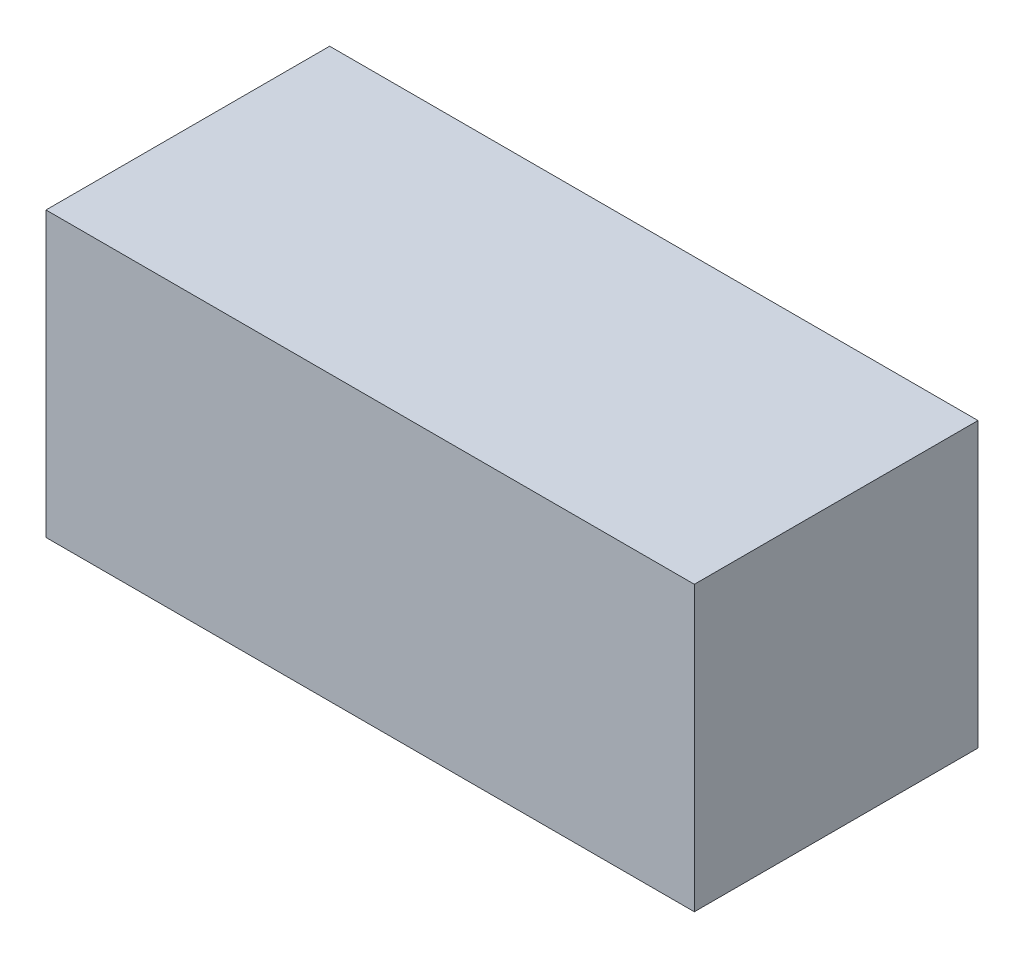
from build123d import *

# Parameters (mm, degrees)
SKETCH_1_W      = 160
SKETCH_1_H      = 70
EXTRUDE_1_DEPTH = 70
SKETCH_2_W      = 1.13974359
SKETCH_2_H      = 12.7
EXTRUDE_2_DEPTH = 1


with BuildPart() as part:
    # 스케치1 → 보스-돌출1 (new body)
    with BuildSketch(Plane.XY):
        with Locations((80, -35)):
            Rectangle(SKETCH_1_W, SKETCH_1_H)
    extrude(amount=EXTRUDE_1_DEPTH)

    # 스케치2 → 보스-돌출2 (add)
    with BuildSketch(Plane(origin=(0, 0, 0), x_dir=(-1, 0, 0), z_dir=(0, 0, -1))):
        with BuildLine():
            Line((-138.713958847, -29.383712204), (-139.711234488, -30.146933358))
            add(Edge.make_bspline(
                [(-139.711234488, -30.146933358), (-139.782375854, -30.062148268), (-139.923699447, -29.893721174), (-140.151062839, -29.657212541), (-140.388014515, -29.435632878), (-140.634463897, -29.227926629), (-140.894846988, -29.041357222), (-141.162856172, -28.866202077), (-141.442974793, -28.709201999), (-141.830331087, -28.518836307), (-142.33705328, -28.320185973), (-142.97493741, -28.153622819), (-143.640820539, -28.047591696), (-144.095108972, -28.036107843), (-144.326178398, -28.030266692)],
                knots=[0, 0, 0, 0, 0.00033196, 0.000659444, 0.000983431, 0.001304932, 0.001625525, 0.001943778, 0.002265016, 0.002588143, 0.003238217, 0.003893566, 0.004562806, 0.005255583, 0.005255583, 0.005255583, 0.005255583], degree=3))
            add(Edge.make_bspline(
                [(-144.326178398, -28.030266692), (-144.453480656, -28.031732498), (-144.706903686, -28.034650508), (-145.082999576, -28.073146477), (-145.452072647, -28.127252867), (-145.813882824, -28.207536183), (-146.16796956, -28.309036829), (-146.516647704, -28.430323331), (-146.854869023, -28.580382322), (-147.187312345, -28.746238008), (-147.505825482, -28.933571879), (-147.807196655, -29.137908898), (-148.09032671, -29.356962477), (-148.355439617, -29.591553634), (-148.602806401, -29.840625891), (-148.830634643, -30.106833645), (-149.038135989, -30.389325817), (-149.22942348, -30.684377325), (-149.400738255, -30.99112874), (-149.544175246, -31.310715424), (-149.671193833, -31.637664598), (-149.771702513, -31.975670239), (-149.851257188, -32.322353989), (-149.906148995, -32.678646277), (-149.944207162, -33.043802771), (-149.947110661, -33.291305134), (-149.948574232, -33.416063967)],
                knots=[0, 0, 0, 0, 0.000381746, 0.00075995, 0.001133062, 0.001500343, 0.001870765, 0.002237676, 0.002606812, 0.002979993, 0.003351741, 0.00371443, 0.004071661, 0.004424911, 0.004775707, 0.005123948, 0.005475039, 0.005826461, 0.006178335, 0.006527846, 0.006876532, 0.007229865, 0.007584733, 0.007942761, 0.008310834, 0.008684951, 0.008684951, 0.008684951, 0.008684951], degree=3))
            add(Edge.make_bspline(
                [(-149.948574232, -33.416063967), (-149.943995631, -33.603774757), (-149.935006156, -33.972319993), (-149.855002201, -34.51214478), (-149.733426584, -35.029291225), (-149.551215777, -35.520526653), (-149.326538079, -35.991908409), (-149.042636431, -36.43546082), (-148.713827853, -36.85788664), (-148.335460674, -37.249202479), (-147.920330999, -37.606666568), (-147.474931434, -37.921447249), (-147.000371304, -38.183846966), (-146.501890389, -38.402199686), (-145.975652775, -38.570045526), (-145.422604778, -38.688206774), (-144.843949252, -38.765285544), (-144.448546001, -38.772664926), (-144.247312212, -38.776420538)],
                knots=[0, 0, 0, 0, 0.000562815, 0.001105012, 0.001633818, 0.00215373, 0.002673724, 0.003197432, 0.003730267, 0.004277248, 0.00482748, 0.005371661, 0.005910344, 0.006451519, 0.007001839, 0.007564217, 0.008146414, 0.008749794, 0.008749794, 0.008749794, 0.008749794], degree=3))
            add(Edge.make_bspline(
                [(-144.247312212, -38.776420538), (-144.025596741, -38.77029268), (-143.589207654, -38.758231589), (-142.949243673, -38.656053743), (-142.336611038, -38.490380727), (-141.751276795, -38.258522551), (-141.194891079, -37.957114221), (-140.666583197, -37.59172478), (-140.165907213, -37.158878544), (-139.864839989, -36.828376907), (-139.711234488, -36.659753871)],
                knots=[0, 0, 0, 0, 0.000664826, 0.001308536, 0.001938654, 0.00256556, 0.003192755, 0.00383282, 0.004489298, 0.005173128, 0.005173128, 0.005173128, 0.005173128], degree=3))
            Line((-139.711234488, -36.659753871), (-138.713958847, -37.415342813))
            add(Edge.make_bspline(
                [(-138.713958847, -37.415342813), (-138.794215989, -37.518896625), (-138.954345844, -37.72550823), (-139.213636363, -38.016779863), (-139.486785414, -38.290751649), (-139.775821847, -38.545214731), (-140.077420691, -38.785260935), (-140.396997367, -39.004070437), (-140.730350714, -39.20469736), (-141.076351252, -39.388400772), (-141.434631361, -39.551386211), (-141.804761739, -39.690918454), (-142.18514697, -39.811114482), (-142.575804444, -39.910000081), (-142.977544475, -39.987183728), (-143.388917339, -40.038780834), (-143.810810886, -40.074130067), (-144.095441185, -40.077351932), (-144.239680001, -40.07898464)],
                knots=[0, 0, 0, 0, 0.00039295, 0.000784017, 0.001168988, 0.001552873, 0.001938676, 0.002324679, 0.002713864, 0.003105353, 0.00349929, 0.003893826, 0.004291304, 0.004695459, 0.005102104, 0.005517692, 0.005938765, 0.006371376, 0.006371376, 0.006371376, 0.006371376], degree=3))
            add(Edge.make_bspline(
                [(-144.239680001, -40.07898464), (-144.376272736, -40.078033982), (-144.646367954, -40.076154172), (-145.045143424, -40.045702593), (-145.43336276, -40.004156405), (-145.809916403, -39.941599358), (-146.176859226, -39.867778467), (-146.530864776, -39.768822764), (-146.875416539, -39.657972931), (-147.209130232, -39.527689122), (-147.532289714, -39.38067326), (-147.843852687, -39.214515317), (-148.143675856, -39.030612551), (-148.434706955, -38.833018656), (-148.712646758, -38.615386732), (-148.979903836, -38.38073923), (-149.237976821, -38.12986702), (-149.397643707, -37.948965123), (-149.477921187, -37.858011083)],
                knots=[0, 0, 0, 0, 0.000409666, 0.000810065, 0.001199174, 0.001580615, 0.001954827, 0.00232143, 0.002682661, 0.003040299, 0.003395496, 0.003747176, 0.004098847, 0.004450261, 0.004801913, 0.005157073, 0.005516877, 0.005880706, 0.005880706, 0.005880706, 0.005880706], degree=3))
            add(Edge.make_bspline(
                [(-149.477921187, -37.858011083), (-149.60650195, -37.700018769), (-149.862111138, -37.385941562), (-150.189138618, -36.876903859), (-150.469074033, -36.345433501), (-150.695409516, -35.788738331), (-150.872348577, -35.208067526), (-150.994926056, -34.603128373), (-151.074579021, -33.97448584), (-151.083687783, -33.546906636), (-151.088317821, -33.32956557)],
                knots=[0, 0, 0, 0, 0.000610709, 0.001214046, 0.001811469, 0.002410515, 0.003014109, 0.003629806, 0.004260284, 0.004912063, 0.004912063, 0.004912063, 0.004912063], degree=3))
            add(Edge.make_bspline(
                [(-151.088317821, -33.32956557), (-151.08267469, -33.10112721), (-151.071572183, -32.651688998), (-150.977244582, -31.992109225), (-150.825502093, -31.360188434), (-150.60997624, -30.757106275), (-150.336725394, -30.179690687), (-149.999171681, -29.632352601), (-149.601236622, -29.111591642), (-149.146041162, -28.625309545), (-148.64686826, -28.180666751), (-148.112311421, -27.78948424), (-147.543416927, -27.463937825), (-146.946452151, -27.191808893), (-146.316946964, -26.982641841), (-145.656244453, -26.836217421), (-144.965586105, -26.74507817), (-144.494371018, -26.733556701), (-144.254944424, -26.727702589)],
                knots=[0, 0, 0, 0, 0.000685036, 0.001347765, 0.001994424, 0.002631723, 0.003265569, 0.003907406, 0.004557186, 0.005228594, 0.005902557, 0.006560016, 0.007211953, 0.007865497, 0.008525192, 0.009197944, 0.009893113, 0.01061119, 0.01061119, 0.01061119, 0.01061119], degree=3))
            add(Edge.make_bspline(
                [(-144.254944424, -26.727702589), (-144.10902334, -26.729452062), (-143.82018725, -26.732914967), (-143.39291334, -26.766682969), (-142.976925468, -26.822975197), (-142.571937047, -26.899596365), (-142.17597784, -26.994691503), (-141.792074108, -27.118572014), (-141.417973159, -27.260218856), (-141.056034378, -27.423353861), (-140.707994325, -27.606476037), (-140.373961397, -27.807555585), (-140.05658891, -28.026343222), (-139.75364366, -28.260978173), (-139.470193408, -28.516424374), (-139.198190329, -28.785655651), (-138.94687156, -29.076426955), (-138.791738538, -29.281096287), (-138.713958847, -29.383712204)],
                knots=[0, 0, 0, 0, 0.000437698, 0.00086638, 0.001284824, 0.001696468, 0.002102476, 0.002505573, 0.002905769, 0.003302024, 0.003695764, 0.004084948, 0.004470952, 0.004851611, 0.005233595, 0.005614968, 0.005999089, 0.006385327, 0.006385327, 0.006385327, 0.006385327], degree=3))
        make_face()
        Polygon((-136.108830642, -27.053343615), (-134.969087052, -27.053343615), (-134.969087052, -32.263600025), (-128.456266539, -32.263600025), (-128.456266539, -27.053343615), (-127.31652295, -27.053343615), (-127.31652295, -39.753343615), (-128.456266539, -39.753343615), (-128.456266539, -33.566164128), (-134.969087052, -33.566164128), (-134.969087052, -39.753343615), (-136.108830642, -39.753343615), align=None)
        with Locations((-123.490240898, -33.403343615)):
            Rectangle(SKETCH_2_W, SKETCH_2_H)
        Polygon((-119.663958847, -27.053343615), (-118.524215257, -27.053343615), (-118.524215257, -38.450779512), (-113.639599873, -38.450779512), (-113.639599873, -39.753343615), (-119.663958847, -39.753343615), align=None)
        Polygon((-111.522933206, -27.053343615), (-110.383189616, -27.053343615), (-110.383189616, -38.450779512), (-105.498574232, -38.450779512), (-105.498574232, -39.753343615), (-111.522933206, -39.753343615), align=None)
        Polygon((-103.381907565, -27.053343615), (-96.217805001, -27.053343615), (-96.217805001, -28.355907717), (-102.242163975, -28.355907717), (-102.242163975, -32.263600025), (-96.217805001, -32.263600025), (-96.217805001, -33.566164128), (-102.242163975, -33.566164128), (-102.242163975, -38.450779512), (-96.217805001, -38.450779512), (-96.217805001, -39.753343615), (-103.381907565, -39.753343615), align=None)
        with BuildLine():
            Line((-93.938317821, -27.053343615), (-91.396791379, -27.053343615))
            add(Edge.make_bspline(
                [(-91.396791379, -27.053343615), (-91.227187856, -27.05390817), (-90.901530303, -27.054992177), (-90.434993008, -27.061036517), (-90.011077541, -27.078360608), (-89.630005553, -27.093268897), (-89.291784034, -27.120453941), (-88.995375864, -27.14643686), (-88.742146219, -27.180449858), (-88.58885413, -27.212038107), (-88.519447629, -27.22634041)],
                knots=[0, 0, 0, 0, 0.00050882, 0.000976992, 0.001399583, 0.001781609, 0.002120925, 0.002417362, 0.00267425, 0.002886798, 0.002886798, 0.002886798, 0.002886798], degree=3))
            add(Edge.make_bspline(
                [(-88.519447629, -27.22634041), (-88.426532164, -27.24929753), (-88.242683374, -27.294722032), (-87.977978849, -27.390732584), (-87.725741159, -27.501838079), (-87.487018082, -27.632335007), (-87.263005354, -27.783192064), (-87.051393198, -27.951804966), (-86.851221373, -28.137251112), (-86.670585172, -28.344206109), (-86.500263471, -28.561327158), (-86.356613312, -28.796109362), (-86.232782942, -29.041624047), (-86.134192781, -29.300368106), (-86.054806991, -29.569832249), (-85.99883178, -29.852457312), (-85.965263185, -30.146955707), (-85.961845594, -30.347825833), (-85.960112693, -30.449677749)],
                knots=[0, 0, 0, 0, 0.00028695, 0.000567779, 0.000843397, 0.001113237, 0.001382776, 0.001652556, 0.001924343, 0.002200055, 0.002475849, 0.002751185, 0.003024244, 0.003299685, 0.003580653, 0.003866043, 0.004163002, 0.00446846, 0.00446846, 0.00446846, 0.00446846], degree=3))
            add(Edge.make_bspline(
                [(-85.960112693, -30.449677749), (-85.965443058, -30.618896558), (-85.97584398, -30.949086281), (-86.072817927, -31.428278622), (-86.231664156, -31.87527985), (-86.450551519, -32.289527136), (-86.729296474, -32.662945763), (-87.064303573, -32.990933987), (-87.455759706, -33.265398812), (-87.820174652, -33.455727561), (-88.142080463, -33.577621829), (-88.407087055, -33.663388046), (-88.696164373, -33.729652891), (-89.006542701, -33.789016798), (-89.33951368, -33.833835803), (-89.694279251, -33.866662017), (-90.07109243, -33.887178137), (-90.329951339, -33.890233412), (-90.463117501, -33.891805153)],
                knots=[0, 0, 0, 0, 0.00050719, 0.000989658, 0.001459589, 0.001926202, 0.002389733, 0.002852089, 0.003326461, 0.003819151, 0.004080894, 0.004358478, 0.00465405, 0.004969894, 0.005306299, 0.005661468, 0.00603854, 0.006438032, 0.006438032, 0.006438032, 0.006438032], degree=3))
            Line((-90.463117501, -33.891805153), (-85.79729218, -39.753343615))
            Line((-85.79729218, -39.753343615), (-87.206707244, -39.753343615))
            Line((-87.206707244, -39.753343615), (-91.872532565, -33.891805153))
            Line((-91.872532565, -33.891805153), (-92.798574232, -33.891805153))
            Line((-92.798574232, -33.891805153), (-92.798574232, -39.753343615))
            Line((-92.798574232, -39.753343615), (-93.938317821, -39.753343615))
            Line((-93.938317821, -39.753343615), (-93.938317821, -27.053343615))
        make_face()
        with BuildLine():
            Line((-92.798574232, -28.355907717), (-92.798574232, -32.589241051))
            Line((-92.798574232, -32.589241051), (-90.473293783, -32.607049544))
            add(Edge.make_bspline(
                [(-90.473293783, -32.607049544), (-90.364726784, -32.607097574), (-90.15429302, -32.60719067), (-89.849853465, -32.592698968), (-89.56638906, -32.576213213), (-89.304984045, -32.550997017), (-89.065521643, -32.518499271), (-88.848121543, -32.477848442), (-88.652428869, -32.430488101), (-88.42419703, -32.357185058), (-88.169338759, -32.241048935), (-87.892364605, -32.072082697), (-87.656498979, -31.859560464), (-87.457225593, -31.616542495), (-87.297098799, -31.349348107), (-87.184206487, -31.061180138), (-87.112569625, -30.759313483), (-87.104120332, -30.551838634), (-87.099856283, -30.447133679)],
                knots=[0, 0, 0, 0, 0.000325651, 0.000631204, 0.000914157, 0.001177428, 0.001418847, 0.001638891, 0.00184066, 0.002022485, 0.00235726, 0.002678438, 0.002991969, 0.003304683, 0.003618388, 0.003922157, 0.004230116, 0.004543873, 0.004543873, 0.004543873, 0.004543873], degree=3))
            add(Edge.make_bspline(
                [(-87.099856283, -30.447133679), (-87.104218265, -30.345001826), (-87.112862122, -30.14261376), (-87.183433368, -29.846319456), (-87.302774838, -29.566676523), (-87.463601244, -29.304822535), (-87.659541035, -29.067130293), (-87.889294241, -28.863759195), (-88.146578806, -28.695939709), (-88.387048583, -28.588699528), (-88.601984154, -28.522950346), (-88.788600349, -28.476681838), (-88.999461997, -28.43950905), (-89.235592946, -28.409725515), (-89.495985149, -28.384126146), (-89.781955226, -28.366883978), (-90.091605829, -28.356673671), (-90.306224694, -28.356168977), (-90.417324232, -28.355907717)],
                knots=[0, 0, 0, 0, 0.000306146, 0.000606669, 0.000907656, 0.001214825, 0.001525577, 0.001828332, 0.00213176, 0.0024438, 0.002614386, 0.002805665, 0.003020244, 0.003256281, 0.003519552, 0.003805044, 0.004115587, 0.00444887, 0.00444887, 0.00444887, 0.00444887], degree=3))
            Line((-90.417324232, -28.355907717), (-92.798574232, -28.355907717))
        make_face(mode=Mode.SUBTRACT)
        Polygon((-78.958830642, -39.753343615), (-77.282288174, -27.053343615), (-77.119467661, -27.053343615), (-71.876138334, -37.473856435), (-66.64552936, -27.053343615), (-66.480164776, -27.053343615), (-64.793446026, -39.753343615), (-65.938277757, -39.753343615), (-67.154343462, -30.615042333), (-71.738758526, -39.753343615), (-71.995709648, -39.753343615), (-76.597933206, -30.594689769), (-77.811454841, -39.753343615), align=None)
        with BuildLine():
            add(Edge.make_bspline(
                [(-56.245369103, -26.727702589), (-56.010208262, -26.733658814), (-55.548332968, -26.745357332), (-54.869518339, -26.834907222), (-54.221473279, -26.989830494), (-53.598918775, -27.196161888), (-53.009301403, -27.471404943), (-52.448183136, -27.804091053), (-51.916899051, -28.197705632), (-51.422610038, -28.649205969), (-50.97028339, -29.140454502), (-50.571772317, -29.664702918), (-50.237790279, -30.21878143), (-49.963521852, -30.801025015), (-49.748352611, -31.410116899), (-49.599874938, -32.04930428), (-49.505030793, -32.714445699), (-49.493942686, -33.168114608), (-49.488317821, -33.398255474)],
                knots=[0, 0, 0, 0, 0.000705368, 0.001385402, 0.00204938, 0.002701839, 0.003349503, 0.003997423, 0.004655841, 0.005329419, 0.006002834, 0.006656665, 0.007301525, 0.007939971, 0.008584465, 0.009235478, 0.009905767, 0.010595886, 0.010595886, 0.010595886, 0.010595886], degree=3))
            add(Edge.make_bspline(
                [(-49.488317821, -33.398255474), (-49.493941862, -33.626701065), (-49.505027498, -34.07699379), (-49.599982777, -34.737914288), (-49.748902977, -35.373243386), (-49.961523714, -35.981920469), (-50.234484736, -36.564587629), (-50.570690642, -37.119711719), (-50.966717321, -37.647474728), (-51.417410752, -38.14209497), (-51.908723105, -38.595657221), (-52.435701502, -38.990877141), (-52.986494405, -39.330961822), (-53.568189632, -39.602319724), (-54.173072623, -39.819206407), (-54.806557052, -39.967080236), (-55.465674548, -40.06246465), (-55.915149334, -40.073417551), (-56.143606283, -40.07898464)],
                knots=[0, 0, 0, 0, 0.000685036, 0.001350284, 0.001998823, 0.002640075, 0.003280822, 0.003925683, 0.00458358, 0.005257158, 0.005930573, 0.006586435, 0.007230442, 0.007868887, 0.008508583, 0.009154647, 0.009817376, 0.010502411, 0.010502411, 0.010502411, 0.010502411], degree=3))
            add(Edge.make_bspline(
                [(-56.143606283, -40.07898464), (-56.373745955, -40.073362579), (-56.82741251, -40.062280001), (-57.493389752, -39.967278904), (-58.133026137, -39.818720458), (-58.744492497, -39.60641479), (-59.328129813, -39.332032267), (-59.885079542, -38.997462091), (-60.413106162, -38.600470465), (-60.907831928, -38.14992318), (-61.360493304, -37.659443548), (-61.755134467, -37.133902108), (-62.089779878, -36.583609451), (-62.363241113, -36.007038435), (-62.579737866, -35.406976343), (-62.727438206, -34.779420439), (-62.823000089, -34.127948518), (-62.834012246, -33.68438143), (-62.839599873, -33.459313166)],
                knots=[0, 0, 0, 0, 0.000690119, 0.001360408, 0.002013897, 0.002657552, 0.003298299, 0.003945339, 0.004603236, 0.005276814, 0.005950229, 0.006602529, 0.007245213, 0.007879059, 0.008513962, 0.009155077, 0.009810248, 0.010485118, 0.010485118, 0.010485118, 0.010485118], degree=3))
            add(Edge.make_bspline(
                [(-62.839599873, -33.459313166), (-62.837659909, -33.308246052), (-62.833804457, -33.008017604), (-62.787388887, -32.562187369), (-62.720036428, -32.123526983), (-62.623509488, -31.693283828), (-62.49726544, -31.272511113), (-62.348305226, -30.858306916), (-62.166369216, -30.454868833), (-61.960699436, -30.060285668), (-61.731149447, -29.68070841), (-61.477600299, -29.32191678), (-61.208957676, -28.98090002), (-60.914450505, -28.666495178), (-60.603785118, -28.36955591), (-60.27192186, -28.09464548), (-59.920885716, -27.839284943), (-59.549166224, -27.609159706), (-59.165922769, -27.401027989), (-58.770855604, -27.222422987), (-58.36933033, -27.069130135), (-57.959466322, -26.944884855), (-57.542351978, -26.846797181), (-57.117076931, -26.780004784), (-56.683979984, -26.73347083), (-56.39220177, -26.729633609), (-56.245369103, -26.727702589)],
                knots=[0, 0, 0, 0, 0.000453023, 0.000900331, 0.00134327, 0.001783953, 0.002221843, 0.002660465, 0.003103469, 0.003548398, 0.003994743, 0.004433047, 0.004865726, 0.005295975, 0.005724256, 0.006154227, 0.006587795, 0.007025471, 0.007464852, 0.007895214, 0.008325184, 0.00875333, 0.009179133, 0.00960951, 0.010044159, 0.010484467, 0.010484467, 0.010484467, 0.010484467], degree=3))
        make_face()
        with BuildLine():
            add(Edge.make_bspline(
                [(-56.189399552, -28.030266692), (-56.309921222, -28.031735865), (-56.549812368, -28.034660166), (-56.906444828, -28.073180048), (-57.258386988, -28.128079931), (-57.60571153, -28.206390021), (-57.946965209, -28.313084726), (-58.285328918, -28.435878879), (-58.617717142, -28.58545255), (-58.943032569, -28.754444935), (-59.258410128, -28.941493876), (-59.555999073, -29.148220002), (-59.83656981, -29.369775328), (-60.099435377, -29.606676909), (-60.343823916, -29.860131178), (-60.574545547, -30.126295732), (-60.782352315, -30.412778308), (-60.97279998, -30.711810356), (-61.143226143, -31.023002379), (-61.294774716, -31.343078165), (-61.418741262, -31.674648629), (-61.519841884, -32.014116572), (-61.603661198, -32.360944354), (-61.656761437, -32.717763006), (-61.69570457, -33.082779555), (-61.698461723, -33.329456568), (-61.699856283, -33.454225025)],
                knots=[0, 0, 0, 0, 0.000361401, 0.000719348, 0.001074863, 0.001429731, 0.001786237, 0.002146831, 0.002508984, 0.002878794, 0.003246164, 0.003608191, 0.003964987, 0.004318036, 0.004668869, 0.005020697, 0.005373837, 0.005729543, 0.006083645, 0.0064376, 0.006791042, 0.007144375, 0.007499817, 0.007860358, 0.0082259, 0.008600016, 0.008600016, 0.008600016, 0.008600016], degree=3))
            add(Edge.make_bspline(
                [(-61.699856283, -33.454225025), (-61.695230355, -33.637693655), (-61.686129724, -33.998633207), (-61.606455113, -34.52756333), (-61.483729663, -35.035883683), (-61.302818647, -35.520812897), (-61.076574988, -35.986519294), (-60.797077415, -36.42887156), (-60.465937305, -36.847989247), (-60.089786794, -37.240946366), (-59.678587258, -37.599615427), (-59.241951353, -37.914442652), (-58.784556834, -38.180816987), (-58.305210927, -38.397823964), (-57.806472714, -38.569781013), (-57.285128457, -38.687632046), (-56.744651076, -38.765194413), (-56.376239841, -38.772642984), (-56.189399552, -38.776420538)],
                knots=[0, 0, 0, 0, 0.000550108, 0.001082232, 0.001601154, 0.002116289, 0.002631707, 0.003151905, 0.003682739, 0.004231557, 0.004781529, 0.005317417, 0.005844089, 0.006366671, 0.006893638, 0.007423745, 0.007968111, 0.008528275, 0.008528275, 0.008528275, 0.008528275], degree=3))
            add(Edge.make_bspline(
                [(-56.189399552, -38.776420538), (-56.063816503, -38.774695136), (-55.8147476, -38.771273147), (-55.444286705, -38.736806519), (-55.080499879, -38.681536593), (-54.723897378, -38.601959643), (-54.374883919, -38.502365494), (-54.032002777, -38.384046024), (-53.698906123, -38.23643137), (-53.371391855, -38.073334518), (-53.05789692, -37.887405946), (-52.75862856, -37.687696089), (-52.481130005, -37.466467093), (-52.218461089, -37.233085316), (-51.973069189, -36.982845069), (-51.746613732, -36.716071692), (-51.539857252, -36.431081307), (-51.349481906, -36.132502835), (-51.179652924, -35.82045929), (-51.03168305, -35.49922303), (-50.906148573, -35.169585061), (-50.804807998, -34.831069931), (-50.725395037, -34.484320565), (-50.670676471, -34.128872681), (-50.632400707, -33.765437353), (-50.629515713, -33.519623933), (-50.628061411, -33.395711403)],
                knots=[0, 0, 0, 0, 0.00037666, 0.00074703, 0.001115112, 0.001479909, 0.001842294, 0.002203561, 0.002567016, 0.002934509, 0.003300581, 0.003659737, 0.00401296, 0.004364308, 0.004713319, 0.005063497, 0.005413082, 0.005768788, 0.006125121, 0.006478005, 0.006829068, 0.007182401, 0.00753727, 0.007895297, 0.008260839, 0.008632412, 0.008632412, 0.008632412, 0.008632412], degree=3))
            add(Edge.make_bspline(
                [(-50.628061411, -33.395711403), (-50.629516878, -33.272646573), (-50.632404065, -33.028524814), (-50.670658187, -32.66762413), (-50.725452847, -32.314733906), (-50.804420387, -31.971239535), (-50.906202374, -31.637053458), (-51.031704973, -31.312489545), (-51.179697345, -30.996338666), (-51.349544331, -30.689382217), (-51.540464604, -30.394833882), (-51.749086573, -30.113247985), (-51.979012265, -29.849912609), (-52.223672412, -29.59832672), (-52.489178196, -29.363856092), (-52.77432692, -29.146422945), (-53.075656837, -28.940779921), (-53.394707091, -28.755267168), (-53.723978009, -28.583946953), (-54.061848656, -28.437167598), (-54.404491389, -28.312445908), (-54.751034883, -28.206067206), (-55.104395975, -28.12838664), (-55.462187012, -28.073130573), (-55.823912978, -28.034673573), (-56.06718409, -28.031740314), (-56.189399552, -28.030266692)],
                knots=[0, 0, 0, 0, 0.000369031, 0.00073204, 0.001087555, 0.001439943, 0.001788407, 0.002134718, 0.002482986, 0.00283486, 0.003186283, 0.003535331, 0.003885231, 0.004234241, 0.004587492, 0.004946738, 0.005309426, 0.005681174, 0.006053244, 0.006422379, 0.006785362, 0.007146737, 0.00750905, 0.007869591, 0.0082326, 0.008599088, 0.008599088, 0.008599088, 0.008599088], degree=3))
        make_face(mode=Mode.SUBTRACT)
        with BuildLine():
            Line((-46.883189616, -39.753343615), (-46.883189616, -27.053343615))
            Line((-46.883189616, -27.053343615), (-44.318766539, -27.053343615))
            add(Edge.make_bspline(
                [(-44.318766539, -27.053343615), (-44.095721925, -27.054949512), (-43.664800891, -27.058052096), (-43.042092867, -27.077724001), (-42.465934643, -27.112523691), (-41.938221126, -27.163213115), (-41.457503585, -27.225454122), (-41.025128065, -27.303469875), (-40.63885886, -27.395592665), (-40.401298319, -27.474134727), (-40.288958847, -27.511276307)],
                knots=[0, 0, 0, 0, 0.000669134, 0.001292764, 0.001868826, 0.002400433, 0.002882928, 0.003322552, 0.003718071, 0.004072903, 0.004072903, 0.004072903, 0.004072903], degree=3))
            add(Edge.make_bspline(
                [(-40.288958847, -27.511276307), (-40.142020793, -27.567267725), (-39.851476752, -27.67798086), (-39.437793765, -27.886828011), (-39.048356019, -28.123458409), (-38.681075122, -28.388183968), (-38.344340695, -28.688500318), (-38.024997755, -29.011650314), (-37.736110043, -29.369385149), (-37.471557083, -29.754285819), (-37.233030547, -30.161818123), (-37.025697032, -30.591205518), (-36.853506827, -31.040267387), (-36.710565691, -31.507754924), (-36.597911402, -31.994696066), (-36.52105125, -32.501657809), (-36.470356515, -33.026636582), (-36.465261815, -33.382869636), (-36.462676796, -33.563620057)],
                knots=[0, 0, 0, 0, 0.000471477, 0.000932263, 0.001387773, 0.001837613, 0.002288266, 0.002739829, 0.003199145, 0.003665599, 0.004139895, 0.004614383, 0.005094398, 0.005581273, 0.006079917, 0.006592294, 0.007118596, 0.007660698, 0.007660698, 0.007660698, 0.007660698], degree=3))
            add(Edge.make_bspline(
                [(-36.462676796, -33.563620057), (-36.464959049, -33.720596551), (-36.469456468, -34.029935128), (-36.509839985, -34.485832092), (-36.568536918, -34.928204194), (-36.659411579, -35.354944877), (-36.76972927, -35.769792982), (-36.911113477, -36.168327125), (-37.073076563, -36.554203234), (-37.261943265, -36.922203789), (-37.469284862, -37.270849169), (-37.691795187, -37.599508942), (-37.929236911, -37.903493318), (-38.183874207, -38.183722854), (-38.452416493, -38.439775095), (-38.736621921, -38.673788979), (-39.037223848, -38.881185621), (-39.352875899, -39.070114843), (-39.692786425, -39.234925847), (-40.063393711, -39.374371882), (-40.466278271, -39.489929601), (-40.9004512, -39.586343994), (-41.366662677, -39.662824493), (-41.865369781, -39.714083117), (-42.395806289, -39.748746615), (-42.760039623, -39.751781528), (-42.947512533, -39.753343615)],
                knots=[0, 0, 0, 0, 0.000470825, 0.00092781, 0.001372149, 0.001808729, 0.0022358, 0.002659019, 0.003076254, 0.003490407, 0.003898792, 0.004292531, 0.004680333, 0.005054942, 0.00542743, 0.00579259, 0.006158158, 0.00652204, 0.006895248, 0.007289784, 0.007708436, 0.008151601, 0.00862338, 0.009124872, 0.009655071, 0.010217403, 0.010217403, 0.010217403, 0.010217403], degree=3))
            Line((-42.947512533, -39.753343615), (-46.883189616, -39.753343615))
        make_face()
        with BuildLine():
            Line((-45.743446026, -38.450779512), (-44.285693623, -38.450779512))
            add(Edge.make_bspline(
                [(-44.285693623, -38.450779512), (-44.076222106, -38.449879277), (-43.673331666, -38.448147794), (-43.094001219, -38.432954229), (-42.564667409, -38.40812777), (-42.085255075, -38.373383916), (-41.656034901, -38.327414941), (-41.276109865, -38.276161722), (-40.946725357, -38.212308115), (-40.747409971, -38.15442892), (-40.655305001, -38.127682557)],
                knots=[0, 0, 0, 0, 0.000628406, 0.001208655, 0.001738433, 0.002218042, 0.002650422, 0.003033235, 0.00336802, 0.003655635, 0.003655635, 0.003655635, 0.003655635], degree=3))
            add(Edge.make_bspline(
                [(-40.655305001, -38.127682557), (-40.539378087, -38.086855474), (-40.310293171, -38.006176463), (-39.980524662, -37.859010092), (-39.672977817, -37.684686011), (-39.382292868, -37.490912045), (-39.112593289, -37.270853695), (-38.860682925, -37.029296107), (-38.62706896, -36.765009923), (-38.414165042, -36.478323165), (-38.22363491, -36.171020193), (-38.058639306, -35.846122139), (-37.914035178, -35.507188856), (-37.80053857, -35.149015623), (-37.711582022, -34.774804468), (-37.648573011, -34.384529066), (-37.609331011, -33.9782623), (-37.604753757, -33.701938878), (-37.602420385, -33.561075987)],
                knots=[0, 0, 0, 0, 0.000368636, 0.000728467, 0.00108158, 0.001428031, 0.001775294, 0.002124361, 0.00247402, 0.002832229, 0.003194399, 0.003557355, 0.003924487, 0.004298604, 0.004683036, 0.005077441, 0.005483744, 0.005906251, 0.005906251, 0.005906251, 0.005906251], degree=3))
            add(Edge.make_bspline(
                [(-37.602420385, -33.561075987), (-37.604282885, -33.412545929), (-37.607941783, -33.120757318), (-37.653931423, -32.692619652), (-37.721138211, -32.280847006), (-37.818324728, -31.88541184), (-37.94217106, -31.505542676), (-38.09672876, -31.143340453), (-38.273319065, -30.794979929), (-38.483425458, -30.468501516), (-38.713533468, -30.159735092), (-38.968904631, -29.876870112), (-39.245481742, -29.619262223), (-39.540248196, -29.382899574), (-39.861511384, -29.177291379), (-40.201703348, -28.993371136), (-40.565814783, -28.837284901), (-40.819135137, -28.754267314), (-40.94787311, -28.712077589)],
                knots=[0, 0, 0, 0, 0.000445394, 0.00087498, 0.001290296, 0.001696304, 0.002095342, 0.002487525, 0.00287666, 0.003265537, 0.003650709, 0.004030799, 0.004406986, 0.004783646, 0.005162584, 0.005549584, 0.005942765, 0.00634906, 0.00634906, 0.00634906, 0.00634906], degree=3))
            add(Edge.make_bspline(
                [(-40.94787311, -28.712077589), (-41.054375841, -28.682626551), (-41.280829868, -28.620005563), (-41.650361638, -28.551696354), (-42.066250894, -28.491445743), (-42.530344096, -28.440435143), (-43.042112219, -28.403832577), (-43.601948858, -28.376359522), (-44.210095994, -28.357829741), (-44.631672617, -28.356564432), (-44.850477276, -28.355907717)],
                knots=[0, 0, 0, 0, 0.000331365, 0.000704572, 0.001126244, 0.001592052, 0.002104832, 0.002665226, 0.00327352, 0.00392991, 0.00392991, 0.00392991, 0.00392991], degree=3))
            Line((-44.850477276, -28.355907717), (-45.743446026, -28.355907717))
            Line((-45.743446026, -28.355907717), (-45.743446026, -38.450779512))
        make_face(mode=Mode.SUBTRACT)
        with BuildLine():
            Line((-33.857548591, -27.053343615), (-32.717805001, -27.053343615))
            Line((-32.717805001, -27.053343615), (-32.717805001, -34.662658519))
            add(Edge.make_bspline(
                [(-32.717805001, -34.662658519), (-32.717974615, -34.770357188), (-32.718296486, -34.974733974), (-32.716146507, -35.265630379), (-32.71012537, -35.524247587), (-32.706329306, -35.751582477), (-32.69788441, -35.946591875), (-32.690997211, -36.110332288), (-32.682141477, -36.242028394), (-32.67149845, -36.318884897), (-32.666923591, -36.351921339)],
                knots=[0, 0, 0, 0, 0.000323097, 0.000613132, 0.000872677, 0.001099157, 0.001295199, 0.001458198, 0.00159088, 0.001690911, 0.001690911, 0.001690911, 0.001690911], degree=3))
            add(Edge.make_bspline(
                [(-32.666923591, -36.351921339), (-32.648136811, -36.471108166), (-32.611621821, -36.702766069), (-32.518562107, -37.032633263), (-32.388595747, -37.329927412), (-32.234588134, -37.603925525), (-32.031632659, -37.847001203), (-31.788505545, -38.070926343), (-31.493946214, -38.266766891), (-31.166429159, -38.445839837), (-30.813422726, -38.589767422), (-30.452701845, -38.698600487), (-30.089688749, -38.76492678), (-29.84666095, -38.772606793), (-29.725978078, -38.776420538)],
                knots=[0, 0, 0, 0, 0.000361804, 0.000703222, 0.001024581, 0.001333516, 0.001642649, 0.00197037, 0.002321784, 0.002700859, 0.003088736, 0.003463025, 0.003829839, 0.00419167, 0.00419167, 0.00419167, 0.00419167], degree=3))
            add(Edge.make_bspline(
                [(-29.725978078, -38.776420538), (-29.622368791, -38.772523995), (-29.415748638, -38.764753416), (-29.108748161, -38.716633366), (-28.809753481, -38.629908456), (-28.517288157, -38.51800419), (-28.243146013, -38.370148645), (-27.987174095, -38.199348742), (-27.758704962, -37.999012135), (-27.550214513, -37.77730517), (-27.368659174, -37.527152182), (-27.211283889, -37.254000081), (-27.082375516, -36.953738165), (-27.018717583, -36.74272069), (-26.986014135, -36.634313166)],
                knots=[0, 0, 0, 0, 0.000310887, 0.000619979, 0.000929248, 0.001243418, 0.001557536, 0.001861656, 0.002164646, 0.002467059, 0.002772877, 0.003089693, 0.003411052, 0.003750569, 0.003750569, 0.003750569, 0.003750569], degree=3))
            add(Edge.make_bspline(
                [(-26.986014135, -36.634313166), (-26.975127966, -36.589505482), (-26.950869195, -36.489655905), (-26.928201346, -36.320850079), (-26.904591954, -36.121680101), (-26.888210514, -35.890714952), (-26.872240371, -35.628728565), (-26.862686079, -35.334356145), (-26.858269988, -35.008666602), (-26.856953976, -34.781383186), (-26.856266539, -34.662658519)],
                knots=[0, 0, 0, 0, 0.000138249, 0.000308074, 0.000510355, 0.000740013, 0.001002497, 0.001297784, 0.001623465, 0.001979644, 0.001979644, 0.001979644, 0.001979644], degree=3))
            Line((-26.856266539, -34.662658519), (-26.856266539, -27.053343615))
            Line((-26.856266539, -27.053343615), (-25.71652295, -27.053343615))
            Line((-25.71652295, -27.053343615), (-25.71652295, -34.723716211))
            add(Edge.make_bspline(
                [(-25.71652295, -34.723716211), (-25.717445043, -34.8619589), (-25.719244566, -35.131747914), (-25.734849515, -35.527085702), (-25.759730629, -35.902109377), (-25.794884548, -36.25686935), (-25.841464531, -36.590096157), (-25.893263188, -36.904710601), (-25.959228922, -37.198454317), (-26.036275835, -37.473617661), (-26.124354138, -37.735547953), (-26.238440591, -37.984136355), (-26.366980919, -38.226940033), (-26.519434088, -38.4602866), (-26.690743962, -38.685209235), (-26.884697204, -38.900343879), (-27.094879159, -39.109128418), (-27.324783847, -39.306207258), (-27.570621467, -39.4869416), (-27.831660742, -39.645864941), (-28.105896449, -39.780207782), (-28.392615735, -39.89079185), (-28.691940957, -39.97393911), (-29.003879663, -40.035897533), (-29.329141878, -40.071103012), (-29.550356488, -40.076335158), (-29.662376315, -40.07898464)],
                knots=[0, 0, 0, 0, 0.000414715, 0.000809341, 0.001186722, 0.001542137, 0.001878541, 0.00219599, 0.002498424, 0.002781137, 0.003053079, 0.003326374, 0.003600686, 0.003876597, 0.004161544, 0.004448032, 0.004744861, 0.005049778, 0.005355596, 0.005659269, 0.00596533, 0.006270545, 0.006579814, 0.006896139, 0.007223722, 0.007559781, 0.007559781, 0.007559781, 0.007559781], degree=3))
            add(Edge.make_bspline(
                [(-29.662376315, -40.07898464), (-29.784547059, -40.076137064), (-30.024245621, -40.070550128), (-30.377443751, -40.038536149), (-30.716040977, -39.978235118), (-31.043613445, -39.901454751), (-31.355701421, -39.795559476), (-31.656486205, -39.671831994), (-31.940816276, -39.519877364), (-32.213304314, -39.350809909), (-32.466668429, -39.160583365), (-32.699250435, -38.953246162), (-32.911434308, -38.73211965), (-33.099643578, -38.494809751), (-33.266996502, -38.243162129), (-33.411160419, -37.976464887), (-33.534942762, -37.694821283), (-33.598829448, -37.499048242), (-33.631126315, -37.40007839)],
                knots=[0, 0, 0, 0, 0.000366567, 0.000719203, 0.001062587, 0.001397642, 0.001727489, 0.002050195, 0.002372249, 0.002693427, 0.003011436, 0.003321374, 0.003627277, 0.003929636, 0.004228811, 0.00453276, 0.004838091, 0.005150256, 0.005150256, 0.005150256, 0.005150256], degree=3))
            add(Edge.make_bspline(
                [(-33.631126315, -37.40007839), (-33.649912003, -37.332468763), (-33.690658579, -37.185821976), (-33.734293231, -36.943119574), (-33.770974756, -36.663665445), (-33.805466353, -36.347440458), (-33.825818857, -35.994199514), (-33.843662135, -35.604095733), (-33.857674294, -35.176657415), (-33.857591663, -34.878916744), (-33.857548591, -34.723716211)],
                knots=[0, 0, 0, 0, 0.000210421, 0.000456408, 0.000738845, 0.001056039, 0.001410405, 0.001800055, 0.002227648, 0.00269322, 0.00269322, 0.00269322, 0.00269322], degree=3))
            Line((-33.857548591, -34.723716211), (-33.857548591, -27.053343615))
        make_face()
        Polygon((-22.460112693, -27.053343615), (-21.320369103, -27.053343615), (-21.320369103, -38.450779512), (-16.435753719, -38.450779512), (-16.435753719, -39.753343615), (-22.460112693, -39.753343615), align=None)
        Polygon((-14.319087052, -27.053343615), (-7.154984488, -27.053343615), (-7.154984488, -28.355907717), (-13.179343462, -28.355907717), (-13.179343462, -32.263600025), (-7.154984488, -32.263600025), (-7.154984488, -33.566164128), (-13.179343462, -33.566164128), (-13.179343462, -38.450779512), (-7.154984488, -38.450779512), (-7.154984488, -39.753343615), (-14.319087052, -39.753343615), align=None)
    extrude(amount=EXTRUDE_2_DEPTH)


solid = part.part
